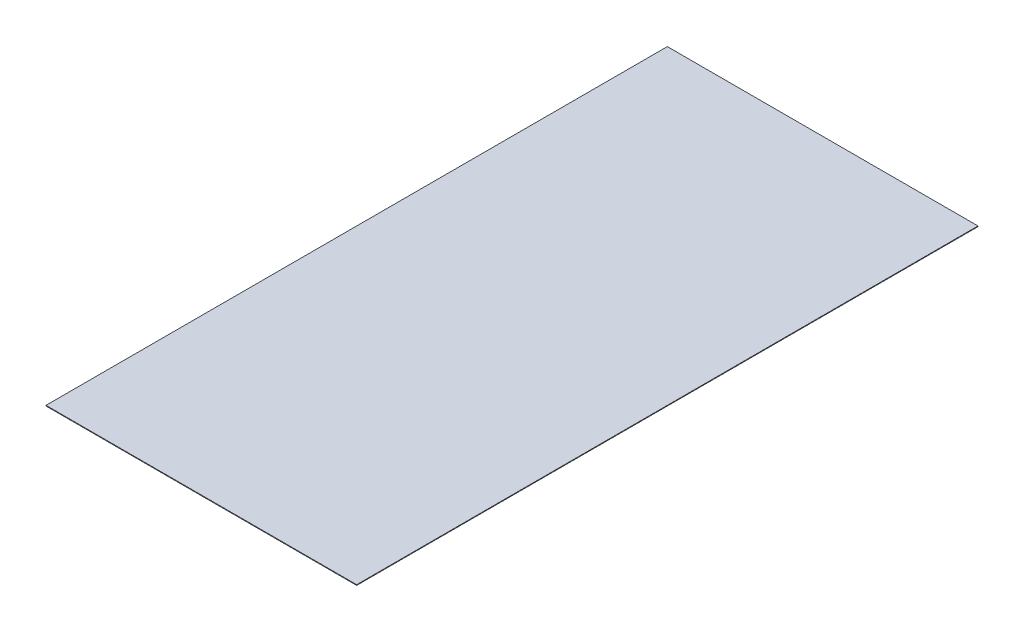
from build123d import *

# Parameters (mm, degrees)
SKETCH1_W           = 50
SKETCH1_H           = 100
BOSS_EXTRUDE1_DEPTH = 0.1


with BuildPart() as part:
    # Sketch1 → Boss-Extrude1 (new body)
    with BuildSketch(Plane(origin=(0, 0, 0), x_dir=(1, 0, 0), z_dir=(0, 1, 0))):
        with Locations((0, -50)):
            Rectangle(SKETCH1_W, SKETCH1_H)
    extrude(amount=BOSS_EXTRUDE1_DEPTH)


solid = part.part
